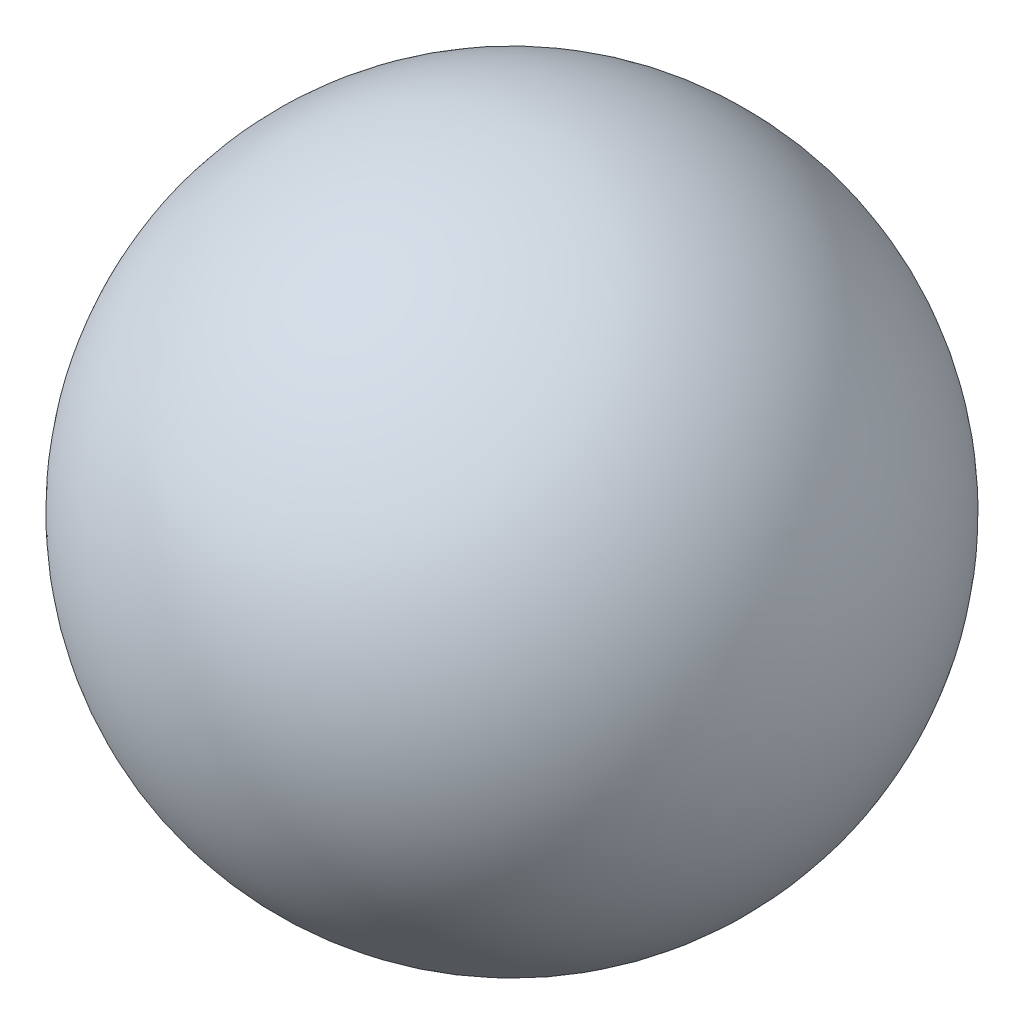
from build123d import *


with BuildPart() as part:
    # Sketch1 → Revolve1 (revolve)
    with BuildSketch(Plane.XY):
        with BuildLine():
            Line((3.3375, 7.325), (0.1625, 7.325))
            ThreePointArc((0.1625, 7.325), (1.75, 8.9125), (3.3375, 7.325))
        make_face()
    revolve(axis=Axis((3.3375, 7.325, 0), (-1, 0, 0)))


solid = part.part
